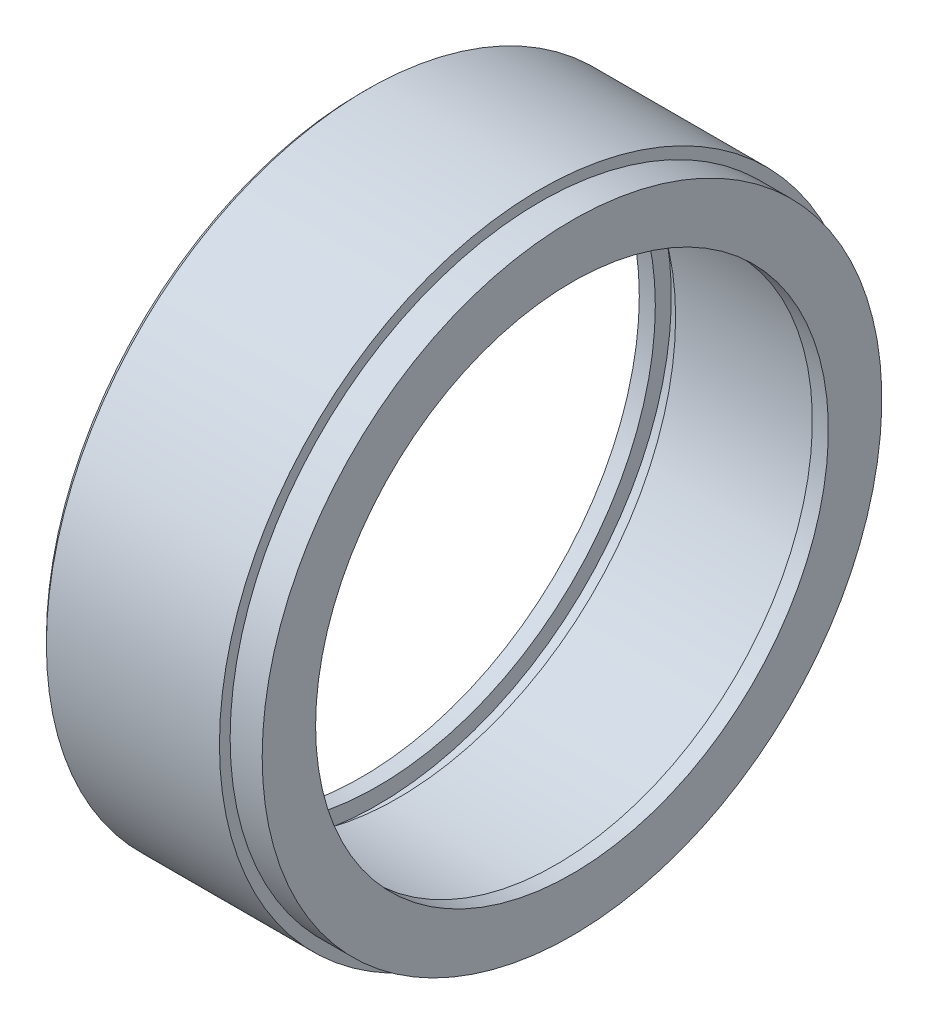
from build123d import *

# Parameters (mm, degrees)
CHAMFER_1_SIZE = 0.5


with BuildPart() as part:
    # Эскиз1 → Повернуть1 (revolve)
    with BuildSketch(Plane.XY):
        Polygon((0, 24), (-1.5, 24), (-1.5, 26), (-16.3, 26), (-16.3, 27.5), (-18.2, 27.5), (-18.2, 26), (-19.7, 26), (-19.7, 30), (-3, 30), (-3, 29), (0, 29), align=None)
    revolve(axis=Axis((-1000, 0, 0), (1, 0, 0)))

    # Фаска1
    chamfer_1_edges = [part.edges().sort_by_distance(p)[0] for p in [
        (-19.7, -30, 0),
    ]]
    chamfer(chamfer_1_edges, length=CHAMFER_1_SIZE)


solid = part.part
